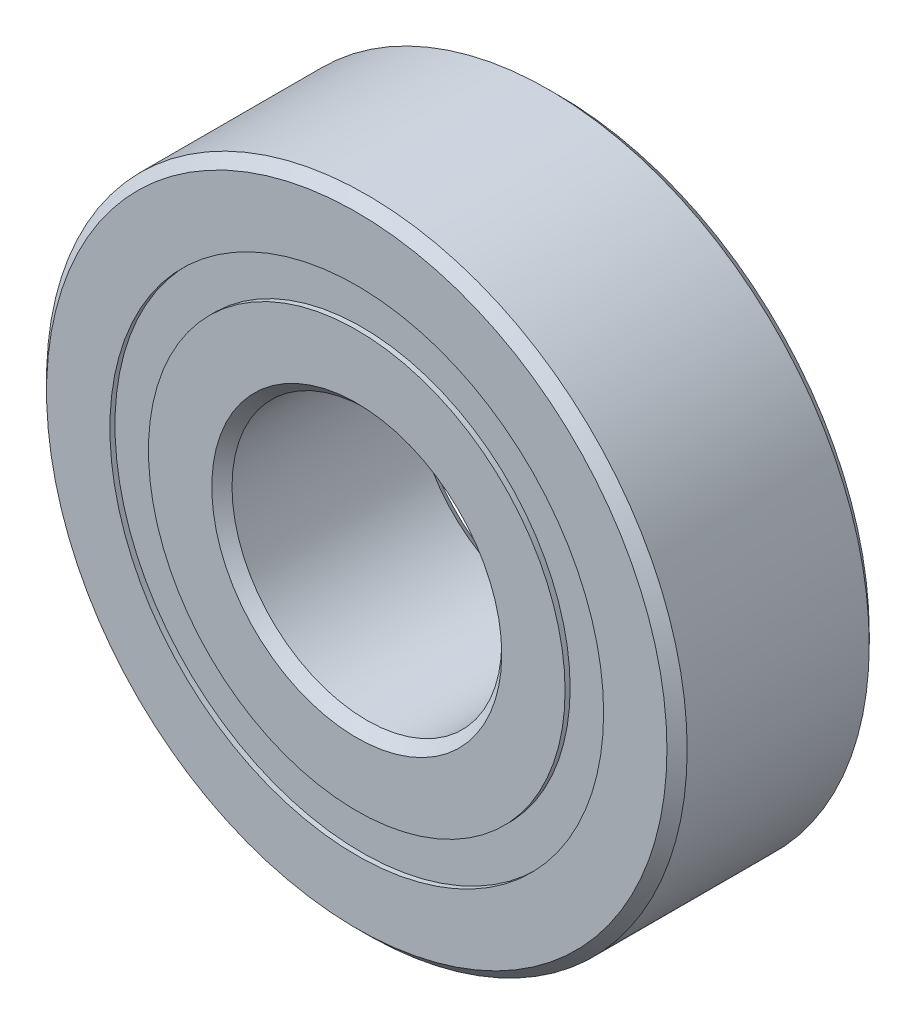
from build123d import *

# Parameters (mm, degrees)
CIRPATTERN1_COUNT = 12
SKETCH5_W         = 1.399376551
SKETCH5_H         = 1.142857142


with BuildPart() as part:
    # Sketch1 → Revolve1 (revolve)
    with BuildSketch(Plane(origin=(0, 0, 0), x_dir=(0, 0, -1), z_dir=(1, 0, 0))):
        with BuildLine():
            Line((2.7, 9.5), (-2.7, 9.5))
            Line((-2.7, 9.5), (-3, 9.2))
            Line((-3, 9.2), (-3, 7.321428571))
            Line((-3, 7.321428571), (-1.333333333, 7.321428571))
            ThreePointArc((-1.333333333, 7.321428571), (0, 8.200623449), (1.333333333, 7.321428571))
            Line((1.333333333, 7.321428571), (3, 7.321428571))
            Line((3, 7.321428571), (3, 9.2))
            Line((3, 9.2), (2.7, 9.5))
        make_face()
    revolve(axis=Axis((0, 0, 3), (0, 0, -1)))


with BuildPart() as body_2:
    # Sketch3 → Revolve3 (revolve)
    with BuildSketch(Plane(origin=(0, 0, 0), x_dir=(0, 0, -1), z_dir=(1, 0, 0))):
        with BuildLine():
            Line((-3, 6.178571429), (-1.333333333, 6.178571429))
            ThreePointArc((-1.333333333, 6.178571429), (0, 5.299376551), (1.333333333, 6.178571429))
            Line((1.333333333, 6.178571429), (3, 6.178571429))
            Line((3, 6.178571429), (3, 4.3))
            Line((3, 4.3), (2.7, 4))
            Line((2.7, 4), (-2.7, 4))
            Line((-2.7, 4), (-3, 4.3))
            Line((-3, 4.3), (-3, 6.178571429))
        make_face()
    revolve(axis=Axis((0, 0, 3), (0, 0, -1)))


with BuildPart() as body_3:
    # Sketch4 → Revolve4 (revolve)
    with BuildSketch(Plane(origin=(0, 0, 0), x_dir=(0, 0, -1), z_dir=(1, 0, 0))):
        with BuildLine():
            Line((-1.450623449, 6.75), (1.450623449, 6.75))
            ThreePointArc((1.450623449, 6.75), (0, 8.200623449), (-1.450623449, 6.75))
        make_face()
    revolve(axis=Axis((0, 6.75, 1.450623449), (0, 0, -1)))


with BuildPart() as cirpattern1_1:
    # CirPattern1: pattern copy
    add(body_3.part.rotate(Axis((0, 0, 0), (0, 0, 1)), 1 * 360 / CIRPATTERN1_COUNT))


with BuildPart() as cirpattern1_2:
    # CirPattern1: pattern copy
    add(body_3.part.rotate(Axis((0, 0, 0), (0, 0, 1)), 2 * 360 / CIRPATTERN1_COUNT))


with BuildPart() as cirpattern1_3:
    # CirPattern1: pattern copy
    add(body_3.part.rotate(Axis((0, 0, 0), (0, 0, 1)), 3 * 360 / CIRPATTERN1_COUNT))


with BuildPart() as cirpattern1_4:
    # CirPattern1: pattern copy
    add(body_3.part.rotate(Axis((0, 0, 0), (0, 0, 1)), 4 * 360 / CIRPATTERN1_COUNT))


with BuildPart() as cirpattern1_5:
    # CirPattern1: pattern copy
    add(body_3.part.rotate(Axis((0, 0, 0), (0, 0, 1)), 5 * 360 / CIRPATTERN1_COUNT))


with BuildPart() as cirpattern1_6:
    # CirPattern1: pattern copy
    add(body_3.part.rotate(Axis((0, 0, 0), (0, 0, 1)), 6 * 360 / CIRPATTERN1_COUNT))


with BuildPart() as cirpattern1_7:
    # CirPattern1: pattern copy
    add(body_3.part.rotate(Axis((0, 0, 0), (0, 0, 1)), 7 * 360 / CIRPATTERN1_COUNT))


with BuildPart() as cirpattern1_8:
    # CirPattern1: pattern copy
    add(body_3.part.rotate(Axis((0, 0, 0), (0, 0, 1)), 8 * 360 / CIRPATTERN1_COUNT))


with BuildPart() as cirpattern1_9:
    # CirPattern1: pattern copy
    add(body_3.part.rotate(Axis((0, 0, 0), (0, 0, 1)), 9 * 360 / CIRPATTERN1_COUNT))


with BuildPart() as cirpattern1_10:
    # CirPattern1: pattern copy
    add(body_3.part.rotate(Axis((0, 0, 0), (0, 0, 1)), 10 * 360 / CIRPATTERN1_COUNT))


with BuildPart() as cirpattern1_11:
    # CirPattern1: pattern copy
    add(body_3.part.rotate(Axis((0, 0, 0), (0, 0, 1)), 11 * 360 / CIRPATTERN1_COUNT))


with BuildPart() as body_15:
    # Sketch5 → Revolve5 (revolve)
    with BuildSketch(Plane(origin=(0, 0, 0), x_dir=(0, 0, -1), z_dir=(1, 0, 0))):
        with Locations((-2.150311724, 6.75)):
            Rectangle(SKETCH5_W, SKETCH5_H)
        with Locations((2.150311724, 6.75)):
            Rectangle(SKETCH5_W, SKETCH5_H)
    revolve(axis=Axis((0, 0, 3), (0, 0, -1)))


solid = Compound([part.part, body_2.part, body_3.part, cirpattern1_1.part, cirpattern1_2.part, cirpattern1_3.part, cirpattern1_4.part, cirpattern1_5.part, cirpattern1_6.part, cirpattern1_7.part, cirpattern1_8.part, cirpattern1_9.part, cirpattern1_10.part, cirpattern1_11.part, body_15.part])
